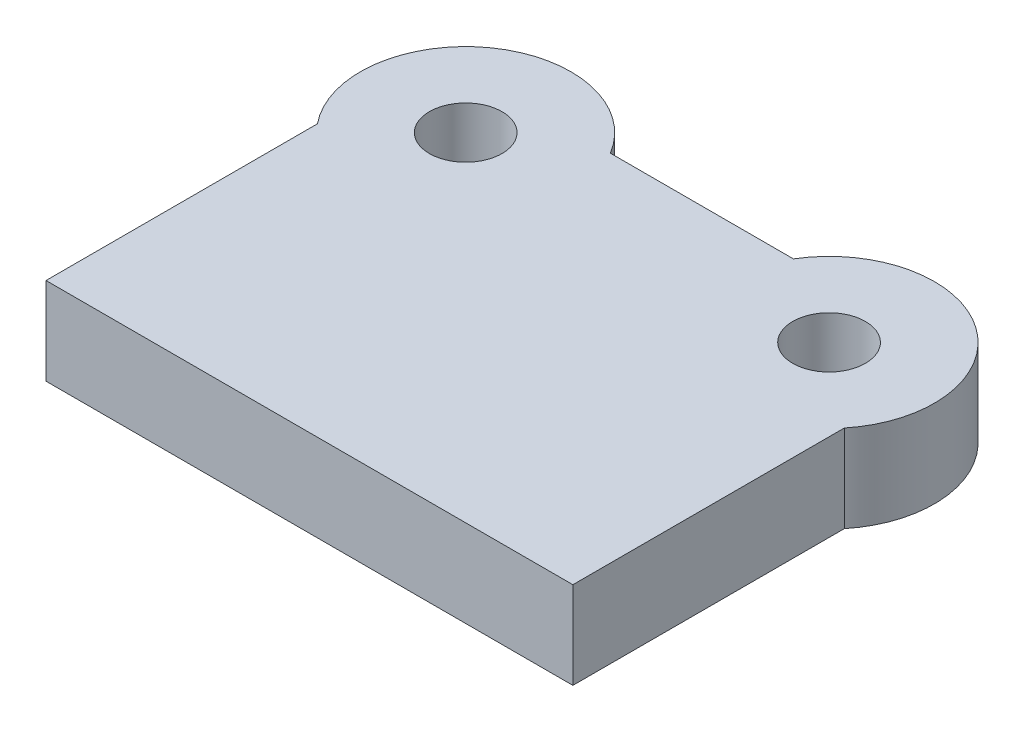
from build123d import *

# Parameters (mm, degrees)
SKETCH1_R           = 10
BOSS_EXTRUDE1_DEPTH = 24


with BuildPart() as part:
    # Sketch1 → Boss-Extrude1 (new body)
    with BuildSketch(Plane(origin=(0, 0, 0), x_dir=(1, 0, 0), z_dir=(0, 1, 0))):
        with BuildLine():
            Line((72.5, 0), (-72.5, 0))
            Line((-72.5, 0), (-72.5, 74.703825536))
            ThreePointArc((-72.5, 74.703825536), (-66.688428669, 116.717005472), (-25.180652708, 108))
            Line((-25.180652708, 108), (25.180652708, 108))
            ThreePointArc((25.180652708, 108), (66.688428669, 116.717005472), (72.5, 74.703825536))
            Line((72.5, 74.703825536), (72.5, 0))
        make_face()
        with Locations((-50, 93)):
            Circle(SKETCH1_R, mode=Mode.SUBTRACT)
        with Locations((50, 93)):
            Circle(SKETCH1_R, mode=Mode.SUBTRACT)
    extrude(amount=BOSS_EXTRUDE1_DEPTH)


solid = part.part
